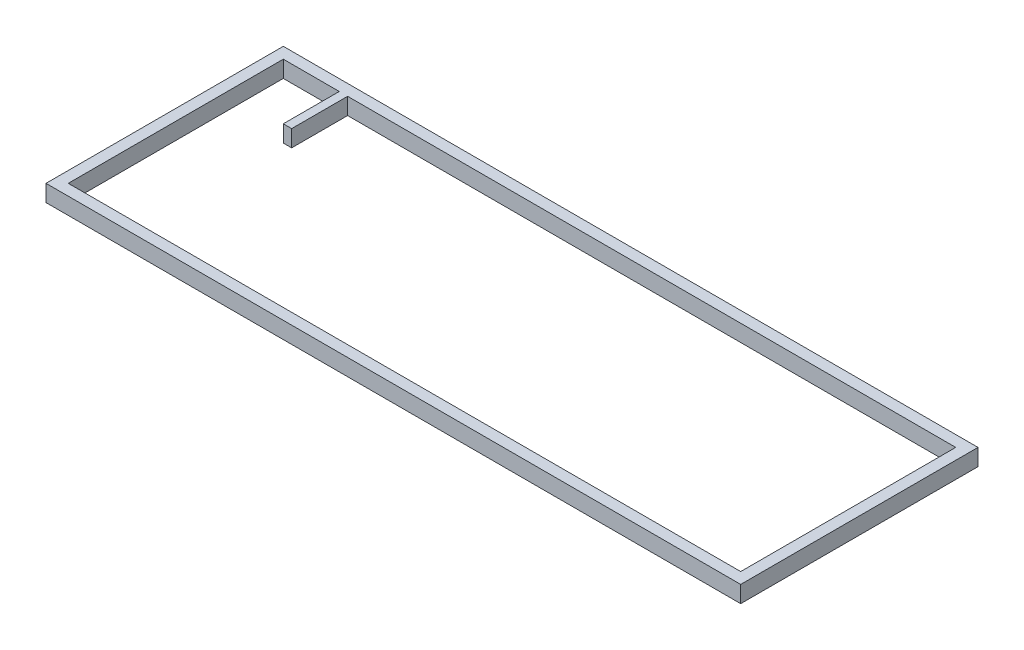
from build123d import *

# Parameters (mm, degrees)
ESQUISSE1_W        = 249.56
ESQUISSE1_H        = 85.25
BOSS_EXTRU_1_DEPTH = 6


with BuildPart() as part:
    # Esquisse1 → Boss.-Extru.1 (new body)
    with BuildSketch(Plane(origin=(0, 0, 0), x_dir=(1, 0, 0), z_dir=(0, 1, 0))):
        with Locations((124.78, 42.625)):
            Rectangle(ESQUISSE1_W, ESQUISSE1_H)
        Polygon((27.1, 81.25), (245.56, 81.25), (245.56, 4), (4, 4), (4, 81.25), (24.1, 81.25), (24.1, 61.15), (27.1, 61.15), align=None, mode=Mode.SUBTRACT)
    extrude(amount=BOSS_EXTRU_1_DEPTH)


solid = part.part
